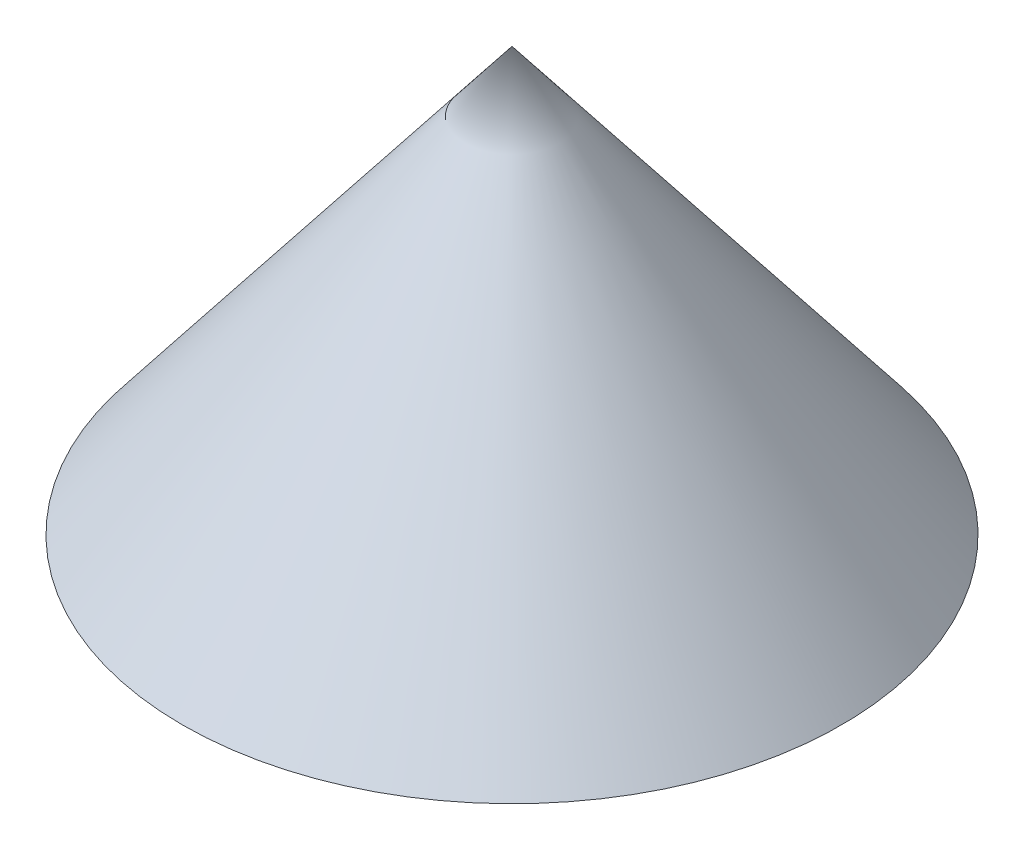
from build123d import *


with BuildPart() as part:
    # Sketch1 → Revolve1 (revolve)
    with BuildSketch(Plane.XY):
        Polygon((0, 0), (0, 55.565626678), (-43.297890918, 0), align=None)
    revolve(axis=Axis((0, -16.236709094, 0), (0, 1, 0)))


solid = part.part
